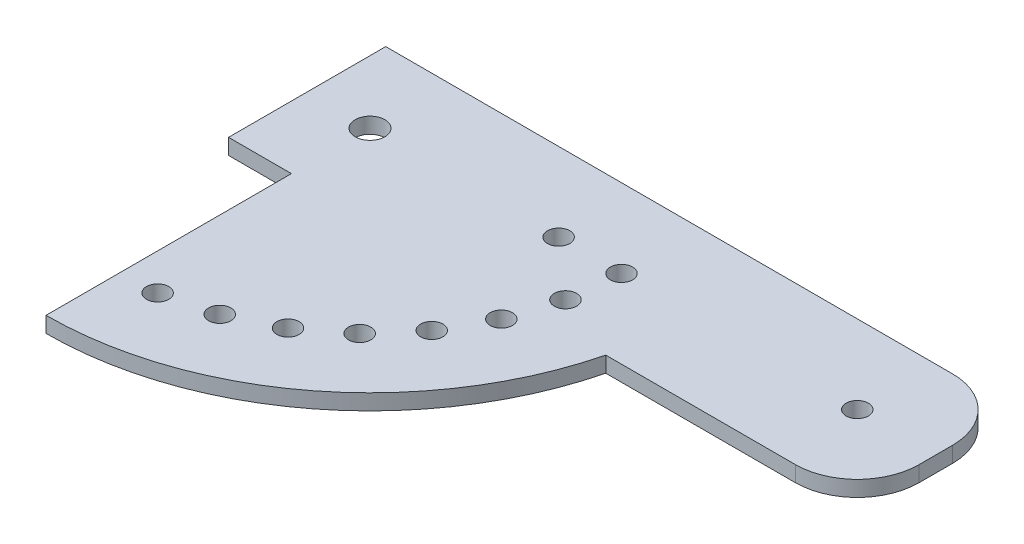
from build123d import *

# Parameters (mm, degrees)
SKETCH1_R           = 3
SKETCH1_R_2         = 2.25
BOSS_EXTRUDE1_DEPTH = 3.175


with BuildPart() as part:
    # Sketch1 → Boss-Extrude1 (new body)
    with BuildSketch(Plane(origin=(0, 0, 0), x_dir=(1, 0, 0), z_dir=(0, 1, 0))):
        with BuildLine():
            Line((-12.7, -15.875), (-12.7, 15.875))
            Line((-12.7, 15.875), (101.8, 15.875))
            ThreePointArc((101.8, 15.875), (110.638834765, 12.213834765), (114.3, 3.375))
            Line((114.3, 3.375), (114.3, -3.375))
            ThreePointArc((114.3, -3.375), (110.638834765, -12.213834765), (101.8, -15.875))
            Line((101.8, -15.875), (63.5, -15.875))
            ThreePointArc((63.5, -15.875), (40.28137649, -51.591436626), (0, -65.454301807))
            Line((0, -65.454301807), (0, -15.875))
            Line((0, -15.875), (-12.7, -15.875))
        make_face()
        Circle(SKETCH1_R, mode=Mode.SUBTRACT)
        with Locations((98.425, 0)):
            Circle(SKETCH1_R_2, mode=Mode.SUBTRACT)
        with Locations((50.8, 0)):
            Circle(SKETCH1_R_2, mode=Mode.SUBTRACT)
        with Locations((49.750497609, -10.272681618)):
            Circle(SKETCH1_R_2, mode=Mode.SUBTRACT)
        with Locations((46.645354818, -20.120906389)):
            Circle(SKETCH1_R_2, mode=Mode.SUBTRACT)
        with Locations((41.612872995, -29.137755595)):
            Circle(SKETCH1_R_2, mode=Mode.SUBTRACT)
        with Locations((34.860989216, -36.950662117)):
            Circle(SKETCH1_R_2, mode=Mode.SUBTRACT)
        with Locations((26.66868451, -43.236804536)):
            Circle(SKETCH1_R_2, mode=Mode.SUBTRACT)
        with Locations((17.374456649, -47.736445785)):
            Circle(SKETCH1_R_2, mode=Mode.SUBTRACT)
        with Locations((7.362333757, -50.263665223)):
            Circle(SKETCH1_R_2, mode=Mode.SUBTRACT)
        with Locations((38.1, 0)):
            Circle(SKETCH1_R_2, mode=Mode.SUBTRACT)
    extrude(amount=BOSS_EXTRUDE1_DEPTH)


solid = part.part
